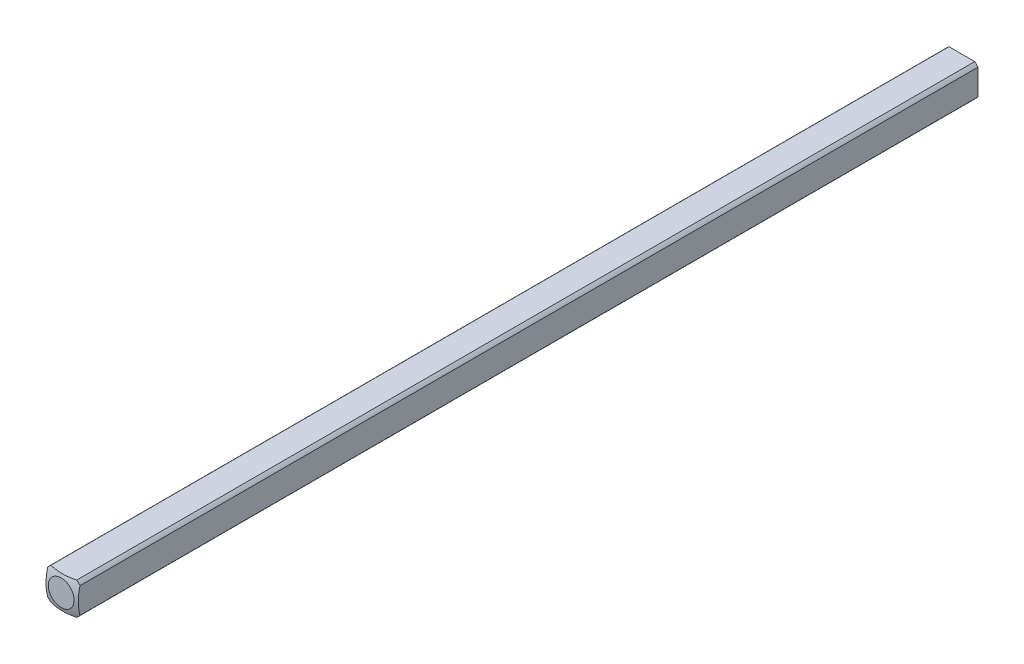
from build123d import *

# Parameters (mm, degrees)
SKETCH1_W           = 3.175
SKETCH1_H           = 3.175
BOSS_EXTRUDE1_DEPTH = 152.4
SKETCH2_OUTSIDE_W   = 35.668
SKETCH2_OUTSIDE_H   = 35.668
SKETCH2_OUTSIDE_R   = 2.032
CUT_EXTRUDE1_DEPTH  = 153.4
CUT_EXTRUDE2_DEPTH  = 4.175
SKETCH6_W           = 3.175
SKETCH6_H           = 12.7
CUT_EXTRUDE3_DEPTH  = 4.175


with BuildPart() as part:
    # Sketch1 → Boss-Extrude1 (new body)
    with BuildSketch(Plane.XY):
        Rectangle(SKETCH1_W, SKETCH1_H)
    extrude(amount=BOSS_EXTRUDE1_DEPTH)

    # Sketch2 outside → Cut-Extrude1 (cut, through all)
    with BuildSketch(Plane(origin=(0, 0, 0), x_dir=(-1, 0, 0), z_dir=(0, 0, -1))):
        Rectangle(SKETCH2_OUTSIDE_W, SKETCH2_OUTSIDE_H)
        Circle(SKETCH2_OUTSIDE_R, mode=Mode.SUBTRACT)
    extrude(amount=-CUT_EXTRUDE1_DEPTH, mode=Mode.SUBTRACT)

    # Sketch3 → Cut-Revolve1 (revolve, cut)
    with BuildSketch(Plane(origin=(0, 0, 0), x_dir=(1, 0, 0), z_dir=(0, 1, 0))):
        with BuildLine():
            Line((-5.053685963, -4.40273269), (-5.053685963, 5.740530545))
            Line((-5.053685963, 5.740530545), (0, 5.740530545))
            Line((0, 5.740530545), (0, 0.160877736))
            ThreePointArc((0, 0.160877736), (-3.404639553, -1.148866368), (-5.053685963, -4.40273269))
        make_face()
    revolve(axis=Axis((0, 0, 152.4), (0, 0, -1)), mode=Mode.SUBTRACT)

    # Mirror1: part across plane


with BuildPart() as part_1:
    add(part.part)
    add(part.part.mirror(Plane(origin=(0, 0, 152.4), x_dir=(1, 0, 0), z_dir=(0, 0, -1))))

    # Sketch4 → Cut-Extrude2 (cut, through all)
    with BuildSketch(Plane(origin=(1.5875, 0, 0), x_dir=(0, 0, -1), z_dir=(1, 0, 0))):
        Polygon((-0.263225358, -1.5875), (-203.463225358, -1.5875), (-203.463225358, 1.5875), (-0.263225358, 1.5875), (0.835678169, 1.5875), (0.835678169, -1.5875), align=None)
    extrude(amount=-CUT_EXTRUDE2_DEPTH, mode=Mode.SUBTRACT)

    # Sketch6 → Cut-Extrude3 (cut, through all)
    with BuildSketch(Plane.XZ.offset(1.5875)):
        with Locations((0, 209.813225358)):
            Rectangle(SKETCH6_W, SKETCH6_H)
    extrude(amount=-CUT_EXTRUDE3_DEPTH, mode=Mode.SUBTRACT)


solid = part_1.part
